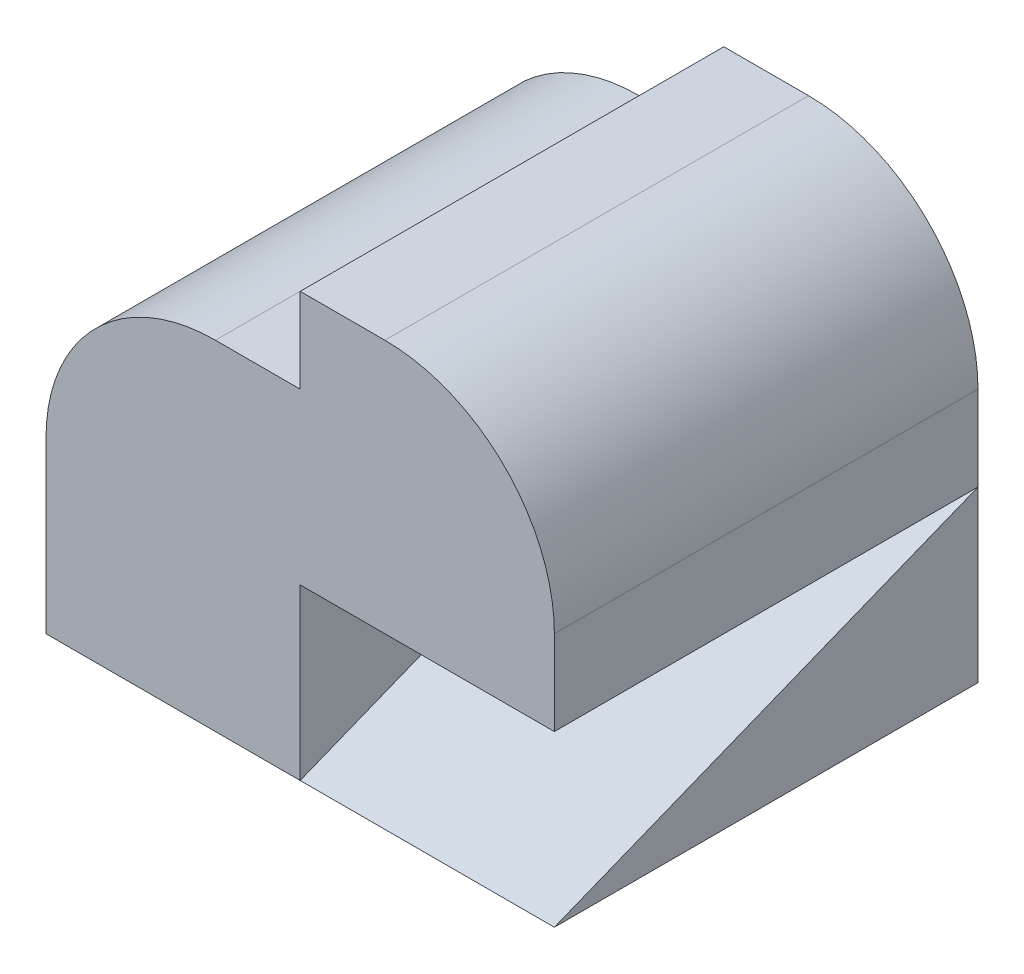
from build123d import *

# Parameters (mm, degrees)
BOSS_EXTRUDE1_DEPTH = 25
BOSS_EXTRUDE3_DEPTH = 25
BOSS_EXTRUDE5_DEPTH = 15


with BuildPart() as part:
    # Sketch1 → Boss-Extrude1 (new body)
    with BuildSketch(Plane.XY):
        with BuildLine():
            Line((-15, 0), (0, 0))
            Line((0, 0), (0, 20))
            Line((0, 20), (-5, 20))
            ThreePointArc((-5, 20), (-12.071067812, 17.071067812), (-15, 10))
            Line((-15, 10), (-15, 0))
        make_face()
    extrude(amount=BOSS_EXTRUDE1_DEPTH)

    # Sketch2 → Boss-Extrude3 (add)
    with BuildSketch(Plane.XY.offset(25)):
        with BuildLine():
            Line((0, 10), (0, 25))
            Line((0, 25), (5, 25))
            ThreePointArc((5, 25), (12.071067812, 22.071067812), (15, 15))
            Line((15, 15), (15, 10))
            Line((15, 10), (0, 10))
        make_face()
    extrude(amount=-BOSS_EXTRUDE3_DEPTH)


with BuildPart() as body_2:
    # Sketch3 → Boss-Extrude5 (new body)
    with BuildSketch(Plane(origin=(0, 0, 0), x_dir=(0, 0, -1), z_dir=(1, 0, 0))):
        Polygon((-25, 0), (0, 10), (0, 0), align=None)
    extrude(amount=BOSS_EXTRUDE5_DEPTH)


solid = Compound([part.part, body_2.part])
